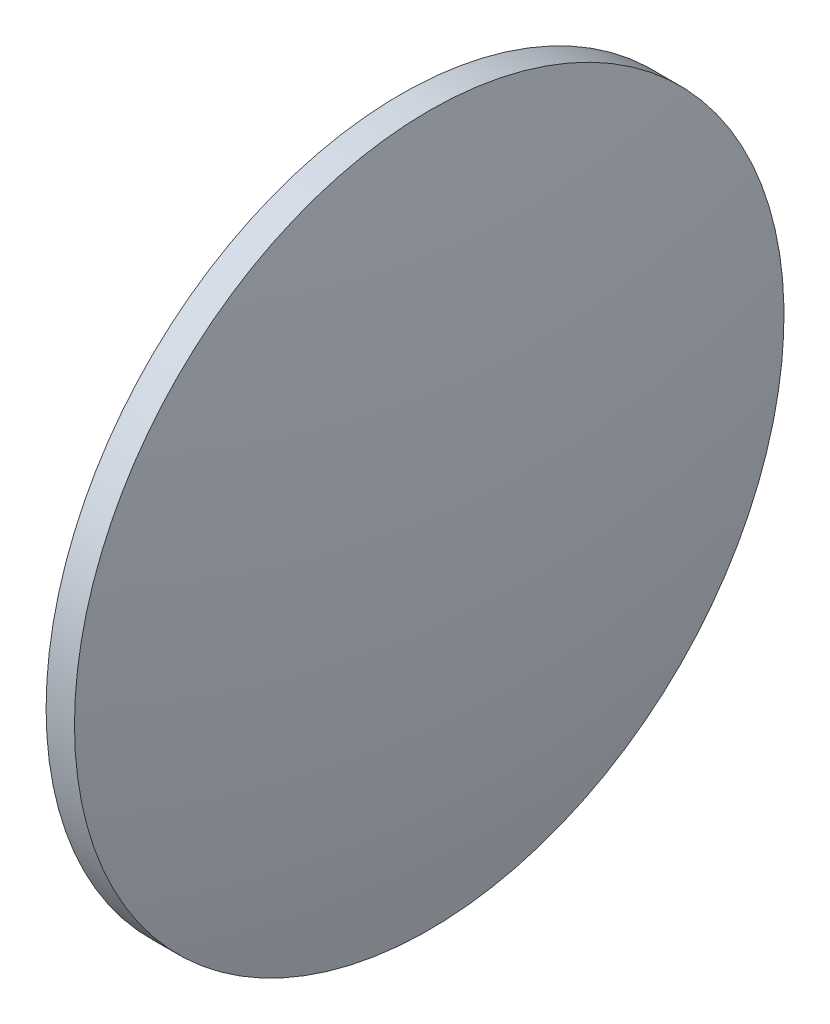
from build123d import *


with BuildPart() as part:
    # 草图1 → 旋转1 (revolve)
    with BuildSketch(Plane.XY):
        with BuildLine():
            Line((235.938907429, 130.04189076), (235.938907429, 180.04189076))
            Line((235.938907429, 180.04189076), (239.938907429, 180.04189076))
            ThreePointArc((239.938907429, 180.04189076), (243.603498072, 155.161166725), (244.828907429, 130.04189076))
            Line((244.828907429, 130.04189076), (235.938907429, 130.04189076))
        make_face()
    revolve(axis=Axis((217.331148661, 130.04189076, 0), (1, 0, 0)))


solid = part.part
